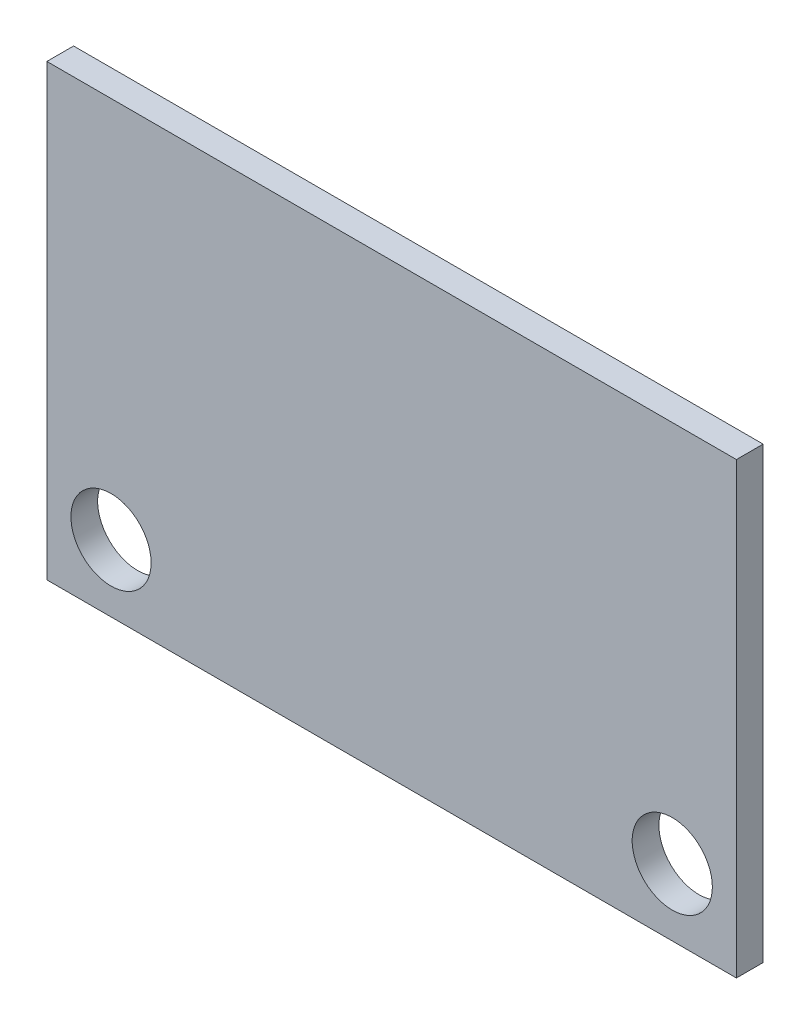
from build123d import *

# Parameters (mm, degrees)
CROQUIS1_W              = 25.8
CROQUIS1_H              = 16.8
CROQUIS1_R              = 1.5
SALIENTE_EXTRUIR1_DEPTH = 1


with BuildPart() as part:
    # Croquis1 → Saliente-Extruir1 (new body)
    with BuildSketch(Plane.XY):
        Rectangle(CROQUIS1_W, CROQUIS1_H)
        with Locations((-10.5, -5.9)):
            Circle(CROQUIS1_R, mode=Mode.SUBTRACT)
        with Locations((10.5, -5.9)):
            Circle(CROQUIS1_R, mode=Mode.SUBTRACT)
    extrude(amount=SALIENTE_EXTRUIR1_DEPTH)


solid = part.part
